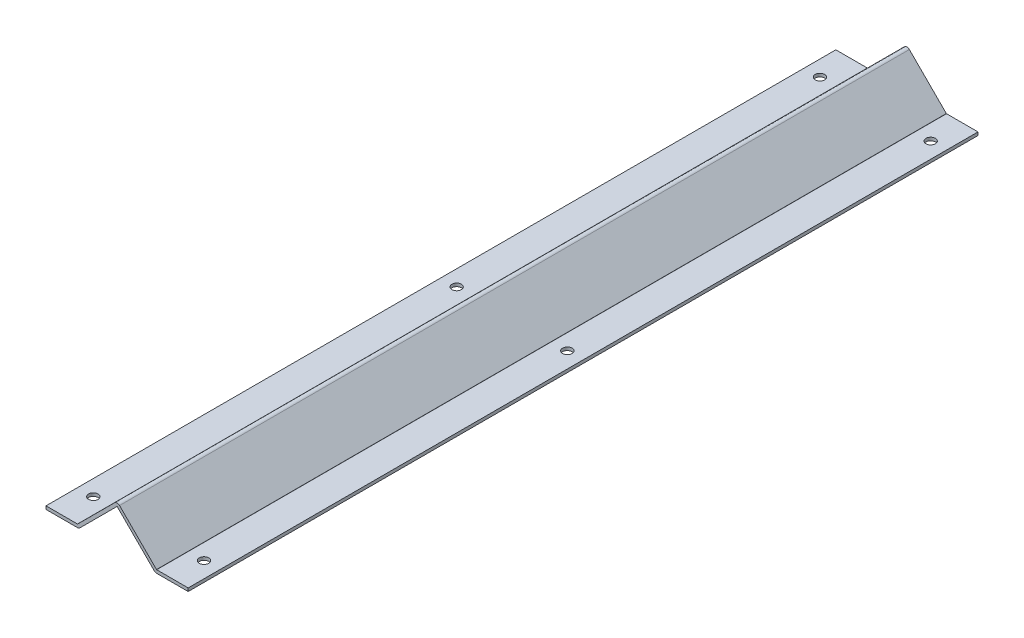
from build123d import *

# Parameters (mm, degrees)
EXTRUDE_1_DEPTH     = 500
CUT_EXTRUDE_1_REACH = 4
SKETCH_2_R          = 3


with BuildPart() as part:
    # 草图1 → 凸台-拉伸1 (new body)
    with BuildSketch(Plane.XY):
        with BuildLine():
            Line((0, 0), (19.917157288, 0))
            ThreePointArc((19.917157288, 0), (19.993693974, 0.015224093), (20.058578644, 0.058578644))
            Line((20.058578644, 0.058578644), (43.444365081, 23.444365081))
            ThreePointArc((43.444365081, 23.444365081), (45, 24.088730163), (46.555634919, 23.444365081))
            Line((46.555634919, 23.444365081), (69.941421356, 0.058578644))
            ThreePointArc((69.941421356, 0.058578644), (70.006306026, 0.015224093), (70.082842712, 0))
            Line((70.082842712, 0), (90, 0))
            Line((90, 0), (90, -2))
            Line((90, -2), (70.082842712, -2))
            ThreePointArc((70.082842712, -2), (69.240939161, -1.832534972), (68.527207794, -1.355634919))
            Line((68.527207794, -1.355634919), (45.141421356, 22.030151519))
            ThreePointArc((45.141421356, 22.030151519), (45, 22.088730163), (44.858578644, 22.030151519))
            Line((44.858578644, 22.030151519), (21.472792206, -1.355634919))
            ThreePointArc((21.472792206, -1.355634919), (20.759060839, -1.832534972), (19.917157288, -2))
            Line((19.917157288, -2), (0, -2))
            Line((0, -2), (0, 0))
        make_face()
    extrude(amount=EXTRUDE_1_DEPTH)

    # 草图2 → 切除-拉伸1 (cut, up to next)
    with BuildSketch(Plane(origin=(0, 0, 0), x_dir=(1, 0, 0), z_dir=(0, 1, 0)), mode=Mode.PRIVATE) as cut_extrude_1_sk1:
        with Locations((9.958578644, -20)):
            Circle(SKETCH_2_R)
    cut_extrude_1_tool1 = extrude(cut_extrude_1_sk1.sketch, amount=-CUT_EXTRUDE_1_REACH, mode=Mode.PRIVATE) & part.part
    add(cut_extrude_1_tool1.solids().sort_by_distance((9.958579, 0, 20))[0], mode=Mode.SUBTRACT)
    # 草图2 → 切除-拉伸1 (cut, up to next)
    with BuildSketch(Plane(origin=(0, 0, 0), x_dir=(1, 0, 0), z_dir=(0, 1, 0)), mode=Mode.PRIVATE) as cut_extrude_1_sk2:
        with Locations((80.041421356, -20)):
            Circle(SKETCH_2_R)
    cut_extrude_1_tool2 = extrude(cut_extrude_1_sk2.sketch, amount=-CUT_EXTRUDE_1_REACH, mode=Mode.PRIVATE) & part.part
    add(cut_extrude_1_tool2.solids().sort_by_distance((80.041421, 0, 20))[0], mode=Mode.SUBTRACT)
    # 草图2 → 切除-拉伸1 (cut, up to next)
    with BuildSketch(Plane(origin=(0, 0, 0), x_dir=(1, 0, 0), z_dir=(0, 1, 0)), mode=Mode.PRIVATE) as cut_extrude_1_sk3:
        with Locations((9.958578644, -250)):
            Circle(SKETCH_2_R)
    cut_extrude_1_tool3 = extrude(cut_extrude_1_sk3.sketch, amount=-CUT_EXTRUDE_1_REACH, mode=Mode.PRIVATE) & part.part
    add(cut_extrude_1_tool3.solids().sort_by_distance((9.958579, 0, 250))[0], mode=Mode.SUBTRACT)
    # 草图2 → 切除-拉伸1 (cut, up to next)
    with BuildSketch(Plane(origin=(0, 0, 0), x_dir=(1, 0, 0), z_dir=(0, 1, 0)), mode=Mode.PRIVATE) as cut_extrude_1_sk4:
        with Locations((80.041421356, -250)):
            Circle(SKETCH_2_R)
    cut_extrude_1_tool4 = extrude(cut_extrude_1_sk4.sketch, amount=-CUT_EXTRUDE_1_REACH, mode=Mode.PRIVATE) & part.part
    add(cut_extrude_1_tool4.solids().sort_by_distance((80.041421, 0, 250))[0], mode=Mode.SUBTRACT)
    # 草图2 → 切除-拉伸1 (cut, up to next)
    with BuildSketch(Plane(origin=(0, 0, 0), x_dir=(1, 0, 0), z_dir=(0, 1, 0)), mode=Mode.PRIVATE) as cut_extrude_1_sk5:
        with Locations((9.958578644, -480)):
            Circle(SKETCH_2_R)
    cut_extrude_1_tool5 = extrude(cut_extrude_1_sk5.sketch, amount=-CUT_EXTRUDE_1_REACH, mode=Mode.PRIVATE) & part.part
    add(cut_extrude_1_tool5.solids().sort_by_distance((9.958579, 0, 480))[0], mode=Mode.SUBTRACT)
    # 草图2 → 切除-拉伸1 (cut, up to next)
    with BuildSketch(Plane(origin=(0, 0, 0), x_dir=(1, 0, 0), z_dir=(0, 1, 0)), mode=Mode.PRIVATE) as cut_extrude_1_sk6:
        with Locations((80.041421356, -480)):
            Circle(SKETCH_2_R)
    cut_extrude_1_tool6 = extrude(cut_extrude_1_sk6.sketch, amount=-CUT_EXTRUDE_1_REACH, mode=Mode.PRIVATE) & part.part
    add(cut_extrude_1_tool6.solids().sort_by_distance((80.041421, 0, 480))[0], mode=Mode.SUBTRACT)


solid = part.part
